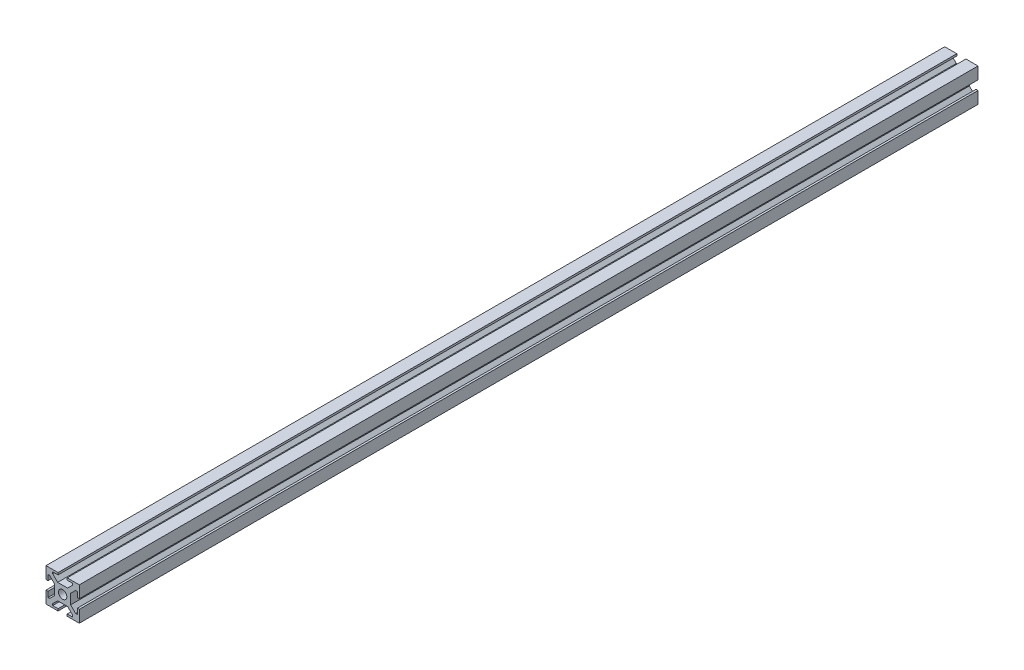
from build123d import *

# Parameters (mm, degrees)
ESQUISSE1_W             = 20
ESQUISSE1_H             = 20
BOSS_EXTRU_1_DEPTH      = 540
ESQUISSE2_W             = 1.2
ESQUISSE2_H             = 5.5
ESQUISSE2_W_2           = 5.5
ESQUISSE2_H_2           = 1.2
ENL_V_MAT_EXTRU_1_DEPTH = 541
ENL_V_MAT_EXTRU_2_DEPTH = 541
ESQUISSE4_R             = 2.5
ENL_V_MAT_EXTRU_3_DEPTH = 541


with BuildPart() as part:
    # Esquisse1 → Boss.-Extru.1 (new body)
    with BuildSketch(Plane.XY):
        with Locations((-12.505109137, -9.909560068)):
            Rectangle(ESQUISSE1_W, ESQUISSE1_H)
    extrude(amount=BOSS_EXTRU_1_DEPTH)

    # Esquisse2 → Enlèv. mat.-Extru.1 (cut, through all)
    with BuildSketch(Plane.XY.offset(540)):
        with Locations((-21.905109137, -9.909560068)):
            Rectangle(ESQUISSE2_W, ESQUISSE2_H)
        with Locations((-12.505109137, -0.509560068)):
            Rectangle(ESQUISSE2_W_2, ESQUISSE2_H_2)
        with Locations((-3.105109137, -9.909560068)):
            Rectangle(ESQUISSE2_W, ESQUISSE2_H)
        with Locations((-12.505109137, -19.309560068)):
            Rectangle(ESQUISSE2_W_2, ESQUISSE2_H_2)
    extrude(amount=-ENL_V_MAT_EXTRU_1_DEPTH, mode=Mode.SUBTRACT)

    # Esquisse3 → Enlèv. mat.-Extru.2 (cut, through all)
    with BuildSketch(Plane.XY.offset(540)):
        Polygon((-21.305109137, -15.909560068), (-20.305109137, -15.909560068), (-17.305109137, -12.909560068), (-17.305109137, -6.909560068), (-20.305109137, -3.909560068), (-21.305109137, -3.909560068), align=None)
        Polygon((-18.505109137, -1.109560068), (-6.505109137, -1.109560068), (-6.505109137, -2.109560068), (-9.505109137, -5.109560068), (-15.505109137, -5.109560068), (-18.505109137, -2.109560068), align=None)
        Polygon((-3.705109137, -3.909560068), (-4.705109137, -3.909560068), (-7.705109137, -6.909560068), (-7.705109137, -12.909560068), (-4.705109137, -15.909560068), (-3.705109137, -15.909560068), align=None)
        Polygon((-6.505109137, -18.709560068), (-18.505109137, -18.709560068), (-18.505109137, -17.709560068), (-15.505109137, -14.709560068), (-9.505109137, -14.709560068), (-6.505109137, -17.709560068), align=None)
    extrude(amount=-ENL_V_MAT_EXTRU_2_DEPTH, mode=Mode.SUBTRACT)

    # Esquisse4 → Enlèv. mat.-Extru.3 (cut, through all)
    with BuildSketch(Plane.XY.offset(540)):
        with Locations((-12.505109137, -9.909560068)):
            Circle(ESQUISSE4_R)
    extrude(amount=-ENL_V_MAT_EXTRU_3_DEPTH, mode=Mode.SUBTRACT)


solid = part.part
